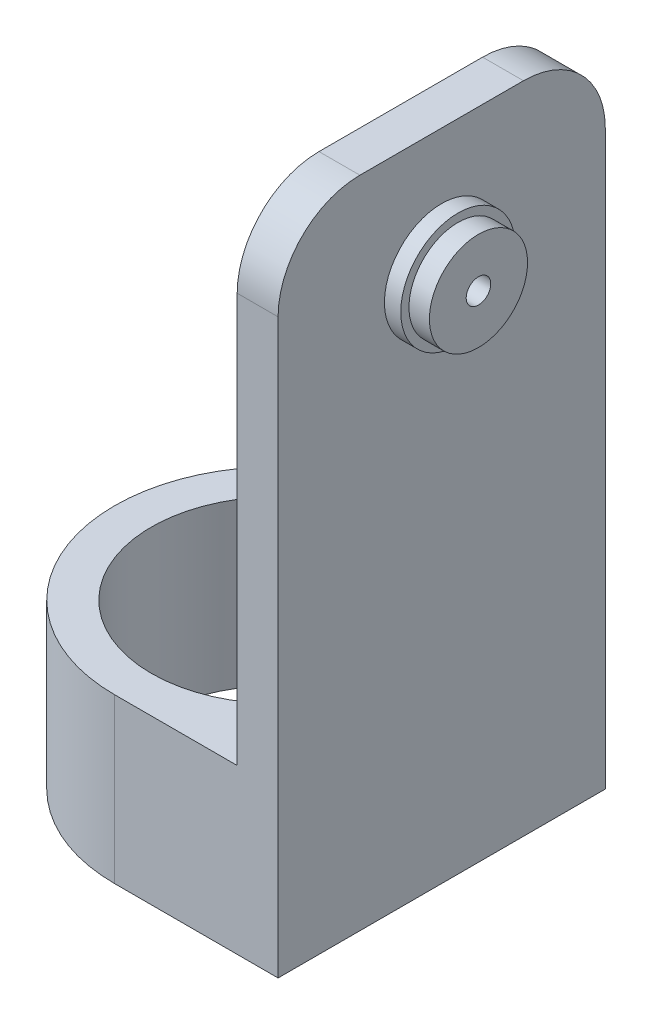
from build123d import *

# Parameters (mm, degrees)
SKETCH_1_R          = 15.5
EXTRUDE_2_DEPTH     = 20
SKETCH_2_W          = 5
SKETCH_2_H          = 40
EXTRUDE_3_DEPTH     = 60
SKETCH_3_R          = 7
EXTRUDE_4_DEPTH     = 2
SKETCH_4_R          = 6
EXTRUDE_5_DEPTH     = 2.5
SKETCH_5_R          = 1.5
CUT_EXTRUDE_1_DEPTH = 45.5
FILLET_1_R          = 10


with BuildPart() as part:
    # Эскиз1 → Бобышка-Вытянуть2 (new body)
    with BuildSketch(Plane(origin=(0, 0, 0), x_dir=(1, 0, 0), z_dir=(0, 1, 0))):
        with BuildLine():
            Line((0, 20), (20, 20))
            Line((20, 20), (20, -20))
            Line((20, -20), (0, -20))
            ThreePointArc((0, -20), (-20, 0), (0, 20))
        make_face()
        Circle(SKETCH_1_R, mode=Mode.SUBTRACT)
    extrude(amount=EXTRUDE_2_DEPTH)

    # Эскиз2 → Бобышка-Вытянуть3 (add)
    with BuildSketch(Plane(origin=(0, 20, 0), x_dir=(1, 0, 0), z_dir=(0, 1, 0))):
        with Locations((17.5, 0)):
            Rectangle(SKETCH_2_W, SKETCH_2_H)
    extrude(amount=EXTRUDE_3_DEPTH)

    # Эскиз3 → Бобышка-Вытянуть4 (add)
    with BuildSketch(Plane(origin=(20, 0, 0), x_dir=(0, 0, -1), z_dir=(1, 0, 0))):
        with Locations((0, 65)):
            Circle(SKETCH_3_R)
    extrude(amount=EXTRUDE_4_DEPTH)

    # Эскиз4 → Бобышка-Вытянуть5 (add)
    with BuildSketch(Plane(origin=(22, 0, 0), x_dir=(0, 0, -1), z_dir=(1, 0, 0))):
        with Locations((0, 65)):
            Circle(SKETCH_4_R)
    extrude(amount=EXTRUDE_5_DEPTH)

    # Эскиз5 → Вырез-Вытянуть1 (cut, through all)
    with BuildSketch(Plane(origin=(24.5, 0, 0), x_dir=(0, 0, -1), z_dir=(1, 0, 0))):
        with Locations((0, 65)):
            Circle(SKETCH_5_R)
    extrude(amount=-CUT_EXTRUDE_1_DEPTH, mode=Mode.SUBTRACT)

    # Скругление1
    fillet_1_edges = [part.edges().sort_by_distance(p)[0] for p in [
        (17.5, 80, -20),
        (17.5, 80, 20),
    ]]
    fillet(fillet_1_edges, radius=FILLET_1_R)


solid = part.part
